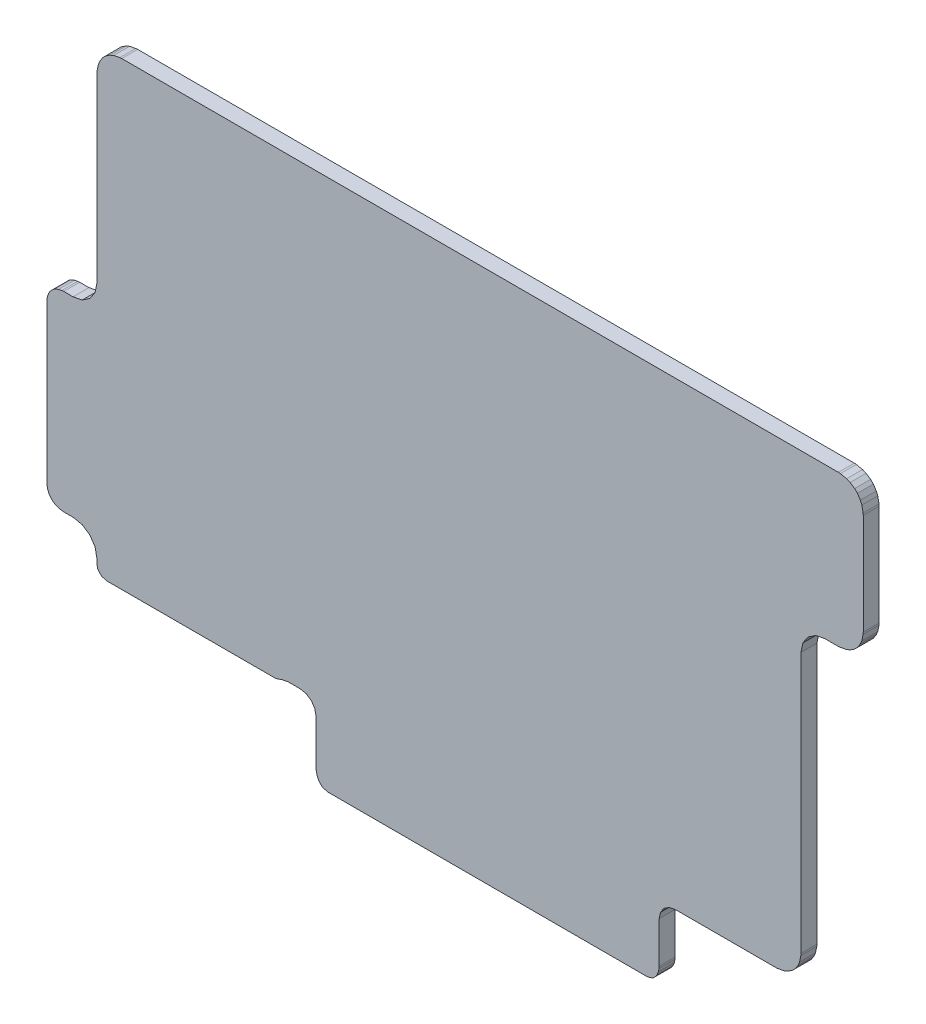
from build123d import *

# Parameters (mm, degrees)
BOSS_EXTRUDE1_DEPTH   = 0.2
BOSS_EXTRUDE1_2_DEPTH = 0.2


with BuildPart() as part:
    # Model → Boss-Extrude1 (new body)
    with BuildSketch(Plane.XY):
        Polygon((16.018, -7.896828787), (16.028, -7.902828787), (21.022, -11.541828787), (21.056, -11.580828787), (21.117, -11.686828787), (21.127, -11.709828787), (21.154, -11.790828787), (21.16, -11.845828787), (21.144, -11.968828787), (21.141, -11.986828787), (21.003, -12.477828787), (21.043, -12.827828787), (21.276, -13.254828787), (21.287, -13.282828787), (21.389, -13.673828787), (21.393, -13.702828787), (21.403, -14.128828787), (21.398, -14.165828787), (21.149, -15.015828787), (21.13, -15.055828787), (20.651, -15.696828787), (20.633, -15.716828787), (20.156, -16.126828787), (20.128, -16.144828787), (19.728, -16.335828787), (19.675, -16.347828787), (19.159, -16.347828787), (19.109, -16.337828787), (18.603, -16.117828787), (18.343, -16.037828787), (17.933, -16.107828787), (17.614, -16.474828787), (17.589, -16.496828787), (16.94, -16.929828787), (16.881, -16.950828787), (14.746, -17.127828787), (14.74, -17.127828787), (10.11, -17.127828787), (10.077, -17.122828787), (9.594, -16.986828787), (9.54, -16.954828787), (8.923, -16.337828787), (8.738, -16.337828787), (8.732, -16.335828787), (-8.046, -16.335828787), (-8.113, -16.315828787), (-8.159, -16.263828787), (-8.17, -16.211828787), (-8.17, -14.262828787), (-8.151, -14.195828787), (-8.098, -14.149828787), (-8.046, -14.138828787), (8.732, -14.138828787), (8.733, -14.137828787), (8.733, -12.396828787), (8.753, -12.329828787), (8.767, -12.311828787), (9.196, -11.856828787), (9.257, -11.821828787), (9.287, -11.817828787), (11.043, -11.817828787), (11.84, -11.212828787), (11.905, -11.187828787), (11.915, -11.187828787), (13.063, -11.187828787), (13.453, -10.907828787), (15.638, -7.967828787), (15.674, -7.934828787), (15.726, -7.903828787), (15.785, -7.886828787), (15.95, -7.879828787), align=None)
    extrude(amount=BOSS_EXTRUDE1_DEPTH)


with BuildPart() as body_2:
    # Model → Boss-Extrude1 2 (new body)
    with BuildSketch(Plane.XY):
        Polygon((4.529, 3.210171213), (4.608, 3.194171213), (4.652, 3.175171213), (4.709, 3.138171213), (4.743, 3.104171213), (4.78, 3.047171213), (4.799, 3.003171213), (4.815, 2.924171213), (4.817, 2.900171213), (4.817, 1.628171213), (4.815, 1.604171213), (4.799, 1.525171213), (4.78, 1.481171213), (4.743, 1.424171213), (4.709, 1.390171213), (4.652, 1.352171213), (4.608, 1.334171213), (4.529, 1.318171213), (4.505, 1.316171213), (4.334, 1.316171213), (4.219, 1.293171213), (4.122, 1.228171213), (4.057, 1.131171213), (4.034, 1.016171213), (4.034, -2.260828787), (4.032, -2.284828787), (4.016, -2.363828787), (3.998, -2.408828787), (3.96, -2.464828787), (3.926, -2.498828787), (3.869, -2.536828787), (3.825, -2.554828787), (3.746, -2.570828787), (3.722, -2.572828787), (2.452, -2.572828787), (2.376, -2.588828787), (2.311, -2.631828787), (2.267, -2.696828787), (2.252, -2.772828787), (2.252, -3.291828787), (2.25, -3.315828787), (2.242, -3.355828787), (2.223, -3.400828787), (2.207, -3.424828787), (2.173, -3.458828787), (2.171, -3.459828787), (2.105, -3.480828787), (2.102, -3.480828787), (-1.915, -3.477828787), (-1.983, -3.458828787), (-2.018, -3.422828787), (-2.033, -3.400828787), (-2.052, -3.355828787), (-2.06, -3.315828787), (-2.062, -3.291828787), (-2.062, -2.727828787), (-2.078, -2.650828787), (-2.121, -2.586828787), (-2.186, -2.542828787), (-2.262, -2.527828787), (-2.417, -2.527828787), (-2.493, -2.542828787), (-2.501, -2.547828787), (-2.568, -2.568828787), (-2.57, -2.568828787), (-4.693, -2.568828787), (-4.76, -2.549828787), (-4.806, -2.496828787), (-4.817, -2.444828787), (-4.817, -2.387828787), (-4.84, -2.272828787), (-4.905, -2.175828787), (-5.002, -2.110828787), (-5.117, -2.087828787), (-5.235, -2.087828787), (-5.259, -2.085828787), (-5.299, -2.076828787), (-5.344, -2.058828787), (-5.368, -2.042828787), (-5.402, -2.008828787), (-5.418, -1.984828787), (-5.437, -1.939828787), (-5.445, -1.899828787), (-5.447, -1.875828787), (-5.447, 0.100171213), (-5.445, 0.124171213), (-5.437, 0.164171213), (-5.418, 0.209171213), (-5.402, 0.233171213), (-5.368, 0.267171213), (-5.344, 0.283171213), (-5.299, 0.302171213), (-5.259, 0.310171213), (-5.235, 0.312171213), (-5.117, 0.312171213), (-5.002, 0.335171213), (-4.905, 0.400171213), (-4.84, 0.497171213), (-4.817, 0.612171213), (-4.817, 2.900171213), (-4.815, 2.924171213), (-4.799, 3.003171213), (-4.78, 3.047171213), (-4.743, 3.104171213), (-4.709, 3.138171213), (-4.652, 3.175171213), (-4.608, 3.194171213), (-4.529, 3.210171213), (-4.505, 3.212171213), (4.505, 3.212171213), align=None)
    extrude(amount=BOSS_EXTRUDE1_2_DEPTH)


solid = body_2.part
